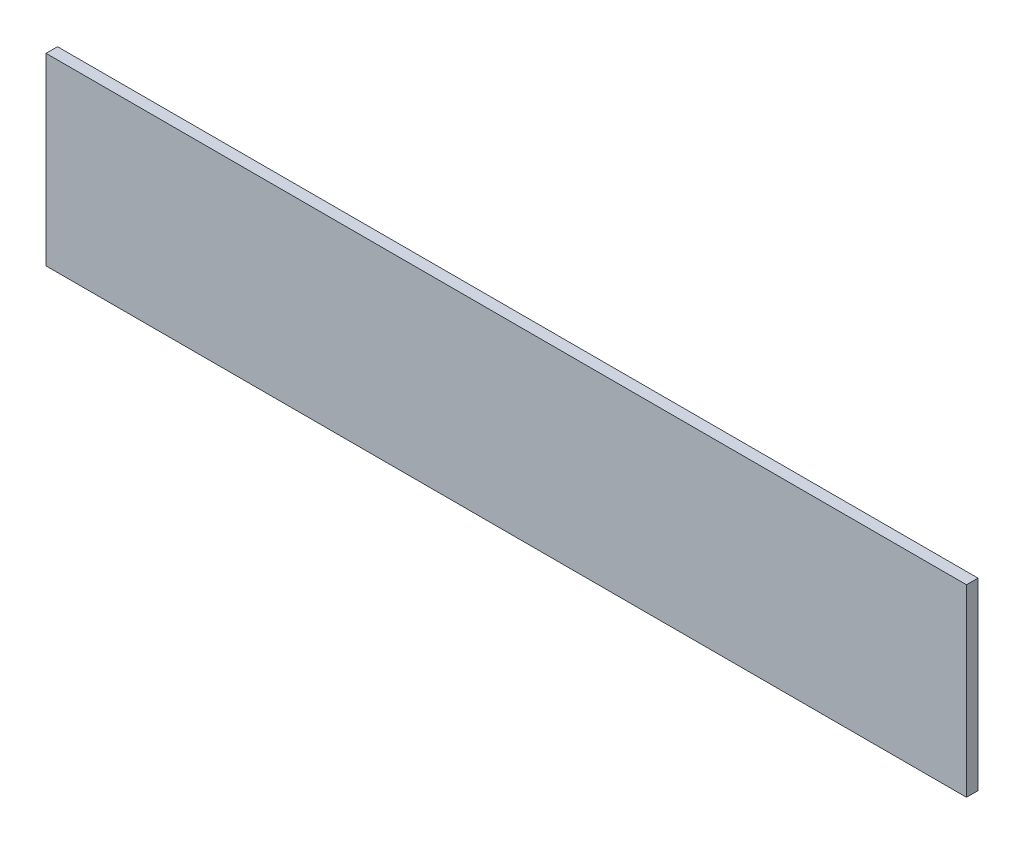
from build123d import *

# Parameters (mm, degrees)
SKETCH1_W           = 254
SKETCH1_H           = 50.8
BOSS_EXTRUDE1_DEPTH = 1.5875


with BuildPart() as part:
    # Sketch1 → Boss-Extrude1 (new body, symmetric)
    with BuildSketch(Plane.XY):
        Rectangle(SKETCH1_W, SKETCH1_H)
    extrude(amount=BOSS_EXTRUDE1_DEPTH, both=True)


solid = part.part
